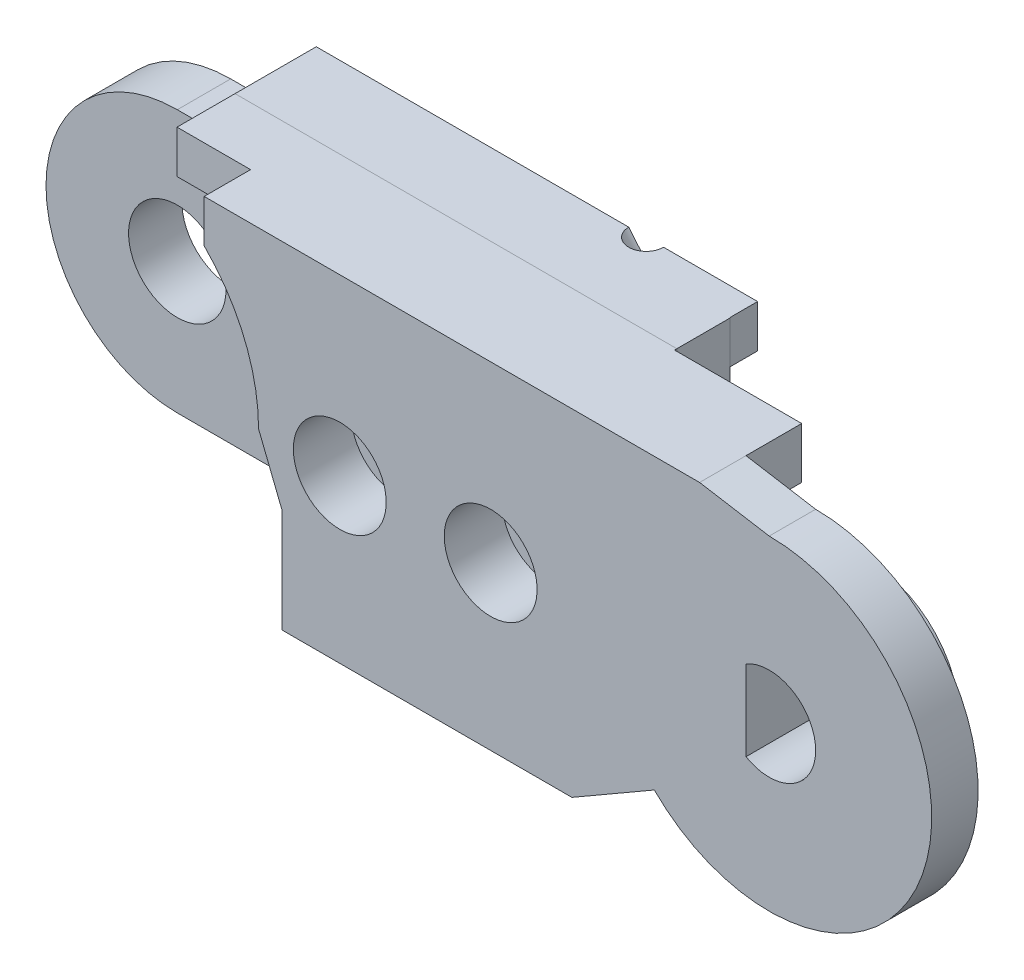
from build123d import *

# Parameters (mm, degrees)
BOSS_EXTRUDE1_DEPTH  = 2
BOSS_EXTRUDE6_DEPTH  = 2.5
CUT_EXTRUDE6_DEPTH   = 2.5
BOSS_EXTRUDE14_DEPTH = 2.3
SKETCH32_R           = 2.1
CUT_EXTRUDE7_DEPTH   = 2.3
SKETCH33_W           = 12.5
SKETCH33_H           = 1.343145751
BOSS_EXTRUDE15_DEPTH = 1.2
SKETCH35_W           = 5.479645997
SKETCH35_H           = 5.327993755
CUT_EXTRUDE8_DEPTH   = 2.4
SKETCH36_W           = 3.7
SKETCH36_H           = 1.827993755
CUT_EXTRUDE9_DEPTH   = 2.4
SKETCH37_R           = 3.9
BOSS_EXTRUDE16_DEPTH = 2.3
CUT_EXTRUDE10_DEPTH  = 5.3
SKETCH43_R           = 2.5
BOSS_EXTRUDE17_DEPTH = 1.2
SKETCH44_R           = 0.95
CUT_EXTRUDE11_DEPTH  = 9
SKETCH45_R           = 2
CUT_EXTRUDE12_DEPTH  = 2.5
SKETCH52_R           = 0.75
CUT_EXTRUDE13_DEPTH  = 10


with BuildPart() as part:
    # Sketch3 → Boss-Extrude1 (new body)
    with BuildSketch(Plane.XY):
        with BuildLine():
            Line((8, 0), (9, -2.5))
            Line((9, -2.5), (9, -7))
            Line((9, -7), (21.5, -7))
            Line((21.5, -7), (25.050252532, -4.949747468))
            ThreePointArc((25.050252532, -4.949747468), (36.467156728, -2.678784027), (30, 7))
            Line((30, 7), (27, 7.5))
            Line((27, 7.5), (5.656854249, 7.5))
            Line((5.656854249, 7.5), (5.656854249, 5.656854249))
            ThreePointArc((5.656854249, 5.656854249), (7.39103626, 3.061467459), (8, 0))
        make_face()
    extrude(amount=BOSS_EXTRUDE1_DEPTH)

    # Sketch22 → Boss-Extrude6 (add)
    with BuildSketch(Plane.XY.offset(2)):
        with BuildLine():
            Line((5.656854249, 5.656854249), (2.486790148, 5.656854249))
            Line((2.486790148, 5.656854249), (2.486790148, 7.5))
            Line((2.486790148, 7.5), (5.656854249, 7.5))
            Line((5.656854249, 7.5), (21.5, 7.5))
            Line((21.5, 7.5), (27, 7.5))
            Line((27, 7.5), (27, 2.172006245))
            Line((27, 2.172006245), (23.275126266, 2.172006245))
            Line((23.275126266, 2.172006245), (23.275126266, -5.974873734))
            Line((23.275126266, -5.974873734), (21.5, -7))
            Line((21.5, -7), (9, -7))
            Line((9, -7), (9, -2.5))
            Line((9, -2.5), (8, 0))
            ThreePointArc((8, 0), (7.39103626, 3.061467459), (5.656854249, 5.656854249))
        make_face()
    extrude(amount=BOSS_EXTRUDE6_DEPTH)

    # Sketch26 → Cut-Extrude6 (cut)
    with BuildSketch(Plane.XY.offset(2)):
        Polygon((18.098080448, 5.3), (2.530052458, 5.3), (2.530052458, 4), (18.098080448, 4), (27, 4), (27, 5.3), align=None)
    extrude(amount=CUT_EXTRUDE6_DEPTH, mode=Mode.SUBTRACT)


with BuildPart() as body_2:
    # Sketch31 → Boss-Extrude14 (new body)
    with BuildSketch(Plane.XY.offset(4.5)):
        with BuildLine():
            Line((2.432688066, 5.656854249), (0, 5.656854249))
            ThreePointArc((0, 5.656854249), (-5.656854249, 0), (0, -5.656854249))
            Line((0, -5.656854249), (9, -5.656854249))
            Line((9, -5.656854249), (9, -7))
            Line((9, -7), (21.5, -7))
            Line((21.5, -7), (23.275126266, -5.974873734))
            Line((23.275126266, -5.974873734), (23.275126266, 2.172006245))
            Line((23.275126266, 2.172006245), (27, 2.172006245))
            Line((27, 2.172006245), (27, 7.5))
            Line((27, 7.5), (2.486790148, 7.5))
            Line((2.486790148, 7.5), (2.432688066, 5.656854249))
        make_face()
    extrude(amount=BOSS_EXTRUDE14_DEPTH)

    # Sketch32 → Cut-Extrude7 (cut)
    with BuildSketch(Plane.XY.offset(6.8)):
        Circle(SKETCH32_R)
    extrude(amount=-CUT_EXTRUDE7_DEPTH, mode=Mode.SUBTRACT)

    # Sketch33 → Boss-Extrude15 (add)
    with BuildSketch(Plane.XY.offset(6.8)):
        with Locations((15.25, -6.328427125)):
            Rectangle(SKETCH33_W, SKETCH33_H)
        Polygon((2.486790148, 7.5), (21.5, 7.5), (21.5, 5.656854249), (2.432688066, 5.656854249), align=None)
    extrude(amount=BOSS_EXTRUDE15_DEPTH)


with BuildPart() as cut_extrude8_tool:
    # Sketch35 → Cut-Extrude8 (new body)
    with BuildSketch(Plane.XY.offset(6.8)):
        with Locations((24.260177002, 4.836003123)):
            Rectangle(SKETCH35_W, SKETCH35_H)
    extrude(amount=-CUT_EXTRUDE8_DEPTH)


with BuildPart() as part_1:
    add(part.part)

    # Cut-Extrude8: cut by cut_extrude8_tool
    add(cut_extrude8_tool.part, mode=Mode.SUBTRACT)

    # Sketch36 → Cut-Extrude9 (cut)
    with BuildSketch(Plane.XY.offset(4.4)):
        with Locations((25.15, 3.086003123)):
            Rectangle(SKETCH36_W, SKETCH36_H)
    extrude(amount=-CUT_EXTRUDE9_DEPTH, mode=Mode.SUBTRACT)

    # Sketch37 → Boss-Extrude16 (add)
    with BuildSketch(Plane.XY.offset(2)):
        with Locations((30, 0)):
            Circle(SKETCH37_R)
    extrude(amount=BOSS_EXTRUDE16_DEPTH)

    # Sketch39 → Cut-Extrude10 (cut, through all)
    with BuildSketch(Plane.XY.offset(4.3)):
        with BuildLine():
            Line((29, 1.732050808), (29, -1.732050808))
            ThreePointArc((29, -1.732050808), (32, 0), (29, 1.732050808))
        make_face()
    extrude(amount=-CUT_EXTRUDE10_DEPTH, mode=Mode.SUBTRACT)


with BuildPart() as body_2_1:
    add(body_2.part)

    # Cut-Extrude8: cut by cut_extrude8_tool
    add(cut_extrude8_tool.part, mode=Mode.SUBTRACT)

    # Sketch43 → Boss-Extrude17 (add)
    with BuildSketch(Plane.XY.offset(6.8)):
        with Locations((11.5, 0)):
            Circle(SKETCH43_R)
        with Locations((18, 0)):
            Circle(SKETCH43_R)
    extrude(amount=BOSS_EXTRUDE17_DEPTH)


with BuildPart() as cut_extrude11_tool:
    # Sketch44 → Cut-Extrude11 (new body, through all)
    with BuildSketch(Plane.XY.offset(8)):
        with Locations((11.5, 0)):
            Circle(SKETCH44_R)
        with Locations((18, 0)):
            Circle(SKETCH44_R)
    extrude(amount=-CUT_EXTRUDE11_DEPTH)


with BuildPart() as part_2:
    add(part_1.part)

    # Cut-Extrude11: cut by cut_extrude11_tool
    add(cut_extrude11_tool.part, mode=Mode.SUBTRACT)

    # Sketch45 → Cut-Extrude12 (cut)
    with BuildSketch(Plane(origin=(0, 0, 0), x_dir=(-1, 0, 0), z_dir=(0, 0, -1))):
        with Locations((-11.5, 0)):
            Circle(SKETCH45_R)
        with Locations((-18, 0)):
            Circle(SKETCH45_R)
    extrude(amount=-CUT_EXTRUDE12_DEPTH, mode=Mode.SUBTRACT)


with BuildPart() as body_2_2:
    add(body_2_1.part)

    # Cut-Extrude11: cut by cut_extrude11_tool
    add(cut_extrude11_tool.part, mode=Mode.SUBTRACT)

    # Sketch52 → Cut-Extrude13 (cut, along a direction that is not the sketch's normal)
    with BuildSketch(Plane.XZ.offset(-5.656854249)):
        with Locations((18.235476819, 8)):
            Circle(SKETCH52_R)
    extrude(amount=-CUT_EXTRUDE13_DEPTH, dir=(0.640410196, -0.76803306, 0), mode=Mode.SUBTRACT)


with BuildPart() as body_3:
    # Mirror1: mirrored copy
    add(body_2_2.part.mirror(Plane.XY.offset(8)))


with BuildPart() as body_4:
    # Mirror1 2: mirrored copy
    add(part_2.part.mirror(Plane.XY.offset(8)))


solid = Compound([body_3.part, body_4.part])
